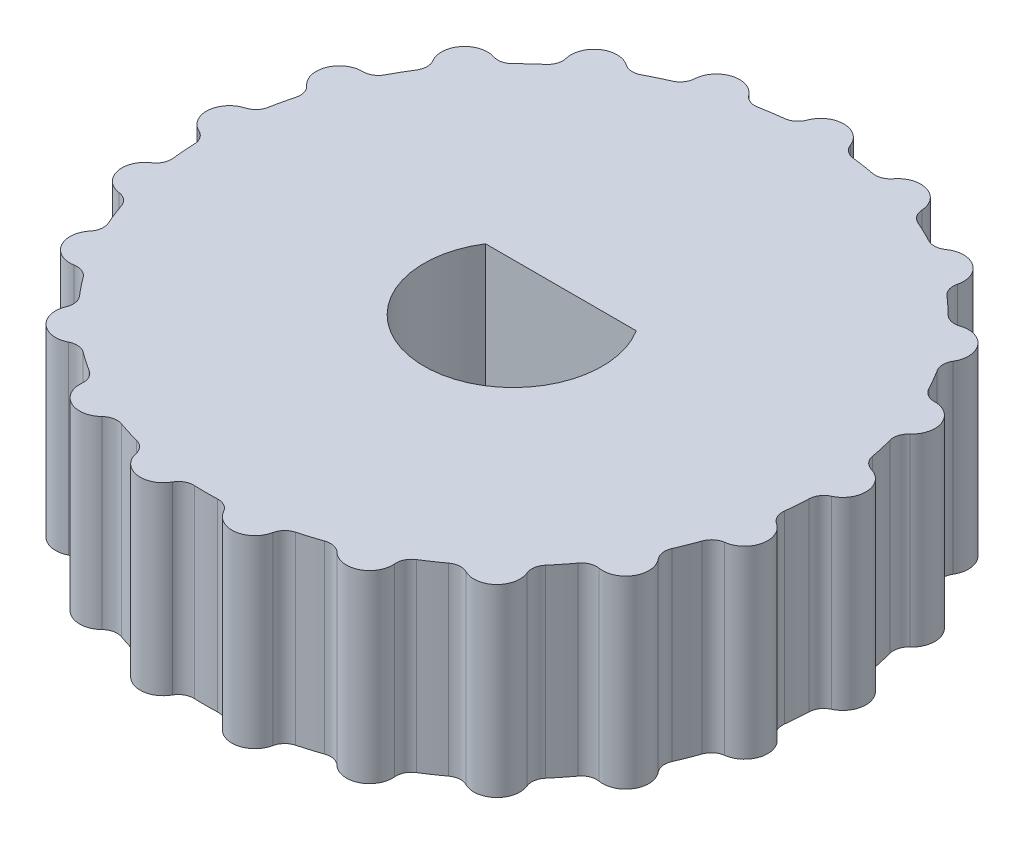
from build123d import *

# Parameters (mm, degrees)
SKETCH1_R                = 10
BOSS_EXTRUDE1_DEPTH      = 6
SKETCH2_R                = 0.75
BOSS_EXTRUDE2_DEPTH      = 6
FILLET1_R                = 0.5
CIRPATTERN1_COUNT        = 21
FILLET1_OF_CIRPATTERN1_R = 0.5


with BuildPart() as part:
    # Sketch1 → Boss-Extrude1 (new body)
    with BuildSketch(Plane(origin=(0, 0, 0), x_dir=(1, 0, 0), z_dir=(0, 1, 0))):
        Circle(SKETCH1_R)
        with BuildLine():
            Line((-2.451020196, 1.55), (2.451020196, 1.55))
            ThreePointArc((2.451020196, 1.55), (0, -2.9), (-2.451020196, 1.55))
        make_face(mode=Mode.SUBTRACT)
    extrude(amount=BOSS_EXTRUDE1_DEPTH)

    # Sketch2 → Boss-Extrude2 (add, through all)
    with BuildSketch(Plane(origin=(0, 6, 0), x_dir=(1, 0, 0), z_dir=(0, 1, 0))):
        with Locations((0, 10)):
            Circle(SKETCH2_R)
    boss_extrude2 = extrude(amount=-BOSS_EXTRUDE2_DEPTH)

    # Fillet1
    fillet1_edges = [part.edges().sort_by_distance(p)[0] for p in [
        (0.749472471, 3, -9.971875),
        (-0.749472471, 3, -9.971875),
    ]]
    fillet(fillet1_edges, radius=FILLET1_R)

    # CirPattern1: Boss-Extrude2 ×21 about axis
    cirpattern1_axis = Axis((0, 0, 0), (0, 1, 0))
    for i in range(1, CIRPATTERN1_COUNT):
        add(boss_extrude2.rotate(cirpattern1_axis, i * 360 / CIRPATTERN1_COUNT))

    # Fillet1 of CirPattern1
    fillet1_of_cirpattern1_edges = [part.edges().sort_by_distance(p)[0] for p in [
        (-2.223086243, 3, -9.749763462),
        (-3.655437267, 3, -9.307941684),
        (-4.998113988, 3, -8.661342653),
        (-6.23660042, 3, -7.816956902),
        (-7.329037372, 3, -6.803323541),
        (-8.263614257, 3, -5.631401195),
        (-9.008743622, 3, -4.340799276),
        (-9.556369702, 3, -2.945470779),
        (-9.887983467, 3, -1.492575946),
        (-9.999999763, 3, 0.002177642),
        (-9.888632588, 3, 1.488269307),
        (-9.55508596, 3, 2.949632569),
        (-9.010633309, 3, 4.336875301),
        (-8.261160838, 3, 5.634999699),
        (-7.331999717, 3, 6.800130892),
        (-6.233195322, 3, 7.819672377),
        (-5.001885774, 3, 8.659165012),
        (-3.651383048, 3, 9.309532848),
        (-2.22733233, 3, 9.74879432),
        (-0.745129366, 3, 9.972200471),
        (0.745129366, 3, 9.972200471),
        (2.22733233, 3, 9.74879432),
        (3.651383048, 3, 9.309532848),
        (5.001885774, 3, 8.659165012),
        (6.233195322, 3, 7.819672377),
        (7.331999717, 3, 6.800130892),
        (8.261160838, 3, 5.634999699),
        (9.010633309, 3, 4.336875301),
        (9.55508596, 3, 2.949632569),
        (9.888632588, 3, 1.488269307),
        (9.999999763, 3, 0.002177642),
        (9.887983467, 3, -1.492575946),
        (9.556369702, 3, -2.945470779),
        (9.008743622, 3, -4.340799276),
        (8.263614257, 3, -5.631401195),
        (7.329037372, 3, -6.803323541),
        (6.23660042, 3, -7.816956902),
        (4.998113988, 3, -8.661342653),
        (3.655437267, 3, -9.307941684),
        (2.223086243, 3, -9.749763462),
    ]]
    fillet(fillet1_of_cirpattern1_edges, radius=FILLET1_OF_CIRPATTERN1_R)


solid = part.part
